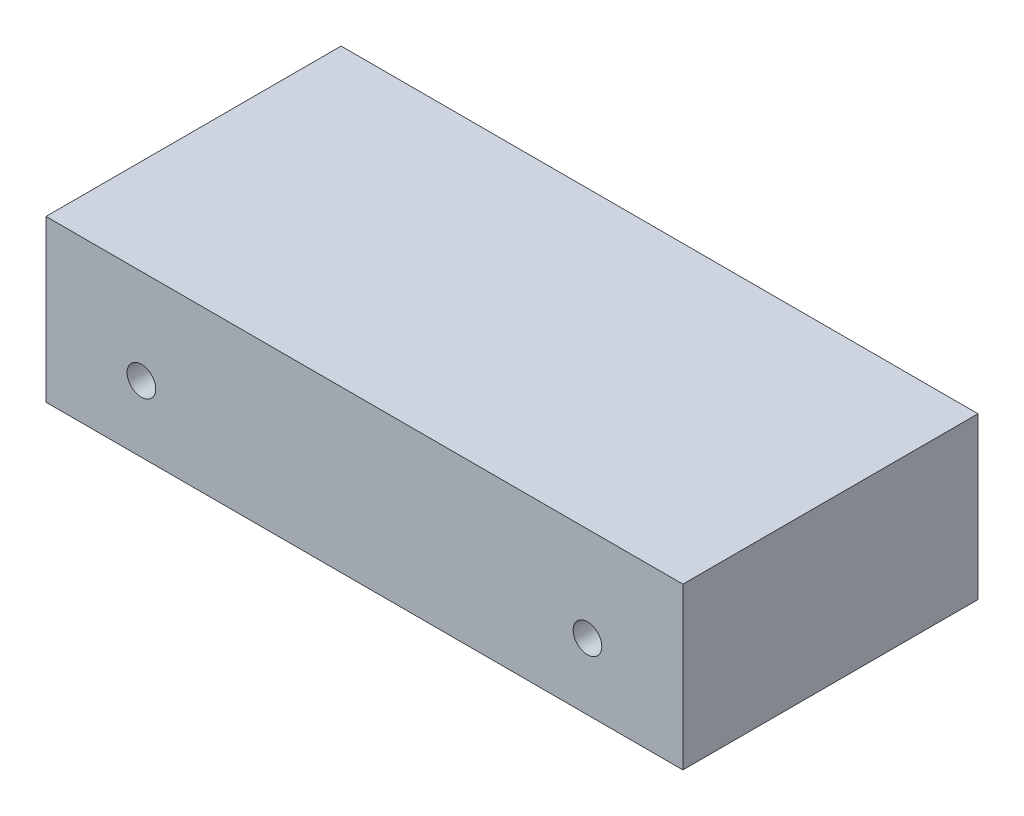
from build123d import *

# Parameters (mm, degrees)
SKETCH1_W           = 310.642
SKETCH1_H           = 78.486
BOSS_EXTRUDE1_DEPTH = 143.9418
SKETCH2_R           = 6.985
CUT_EXTRUDE1_DEPTH  = 25.4


with BuildPart() as part:
    # Sketch1 → Boss-Extrude1 (new body)
    with BuildSketch(Plane.XY):
        Rectangle(SKETCH1_W, SKETCH1_H)
    extrude(amount=BOSS_EXTRUDE1_DEPTH)

    # Sketch2 → Cut-Extrude1 (cut)
    with BuildSketch(Plane.XY.offset(143.9418)):
        with Locations((-108.7882, -6.8834)):
            Circle(SKETCH2_R)
        with Locations((108.7882, -6.8834)):
            Circle(SKETCH2_R)
    extrude(amount=-CUT_EXTRUDE1_DEPTH, mode=Mode.SUBTRACT)


solid = part.part
